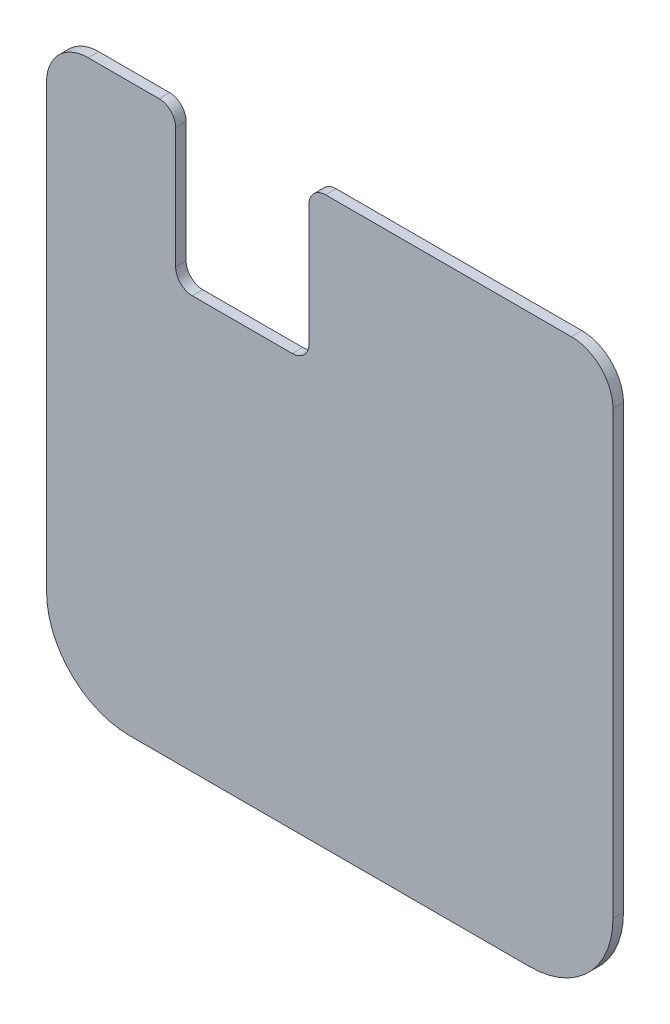
from build123d import *

# Parameters (mm, degrees)
BOARD_DEPTH = 1.6002


with BuildPart() as part:
    # Sketch1 → BOARD (new body)
    with BuildSketch(Plane.XY):
        with BuildLine():
            Line((37.7952, -26.01468), (37.7952, -93.32468))
            ThreePointArc((37.7952, -93.32468), (41.514943879, -102.304936121), (50.4952, -106.02468))
            Line((50.4952, -106.02468), (111.4552, -106.02468))
            ThreePointArc((111.4552, -106.02468), (120.435456121, -102.304936121), (124.1552, -93.32468))
            Line((124.1552, -93.32468), (124.1552, -26.01468))
            ThreePointArc((124.1552, -26.01468), (122.295328061, -21.524551939), (117.8052, -19.66468))
            Line((117.8052, -19.66468), (80.3402, -19.66468))
            ThreePointArc((80.3402, -19.66468), (78.544148776, -20.408628776), (77.8002, -22.20468))
            Line((77.8002, -22.20468), (77.8002, -40.61968))
            ThreePointArc((77.8002, -40.61968), (77.056251224, -42.415731224), (75.2602, -43.15968))
            Line((75.2602, -43.15968), (60.0202, -43.15968))
            ThreePointArc((60.0202, -43.15968), (58.224148776, -42.415731224), (57.4802, -40.61968))
            Line((57.4802, -40.61968), (57.4802, -22.20468))
            ThreePointArc((57.4802, -22.20468), (56.736251224, -20.408628776), (54.9402, -19.66468))
            Line((54.9402, -19.66468), (44.1452, -19.66468))
            ThreePointArc((44.1452, -19.66468), (39.655071939, -21.524551939), (37.7952, -26.01468))
        make_face()
    extrude(amount=BOARD_DEPTH)


solid = part.part
